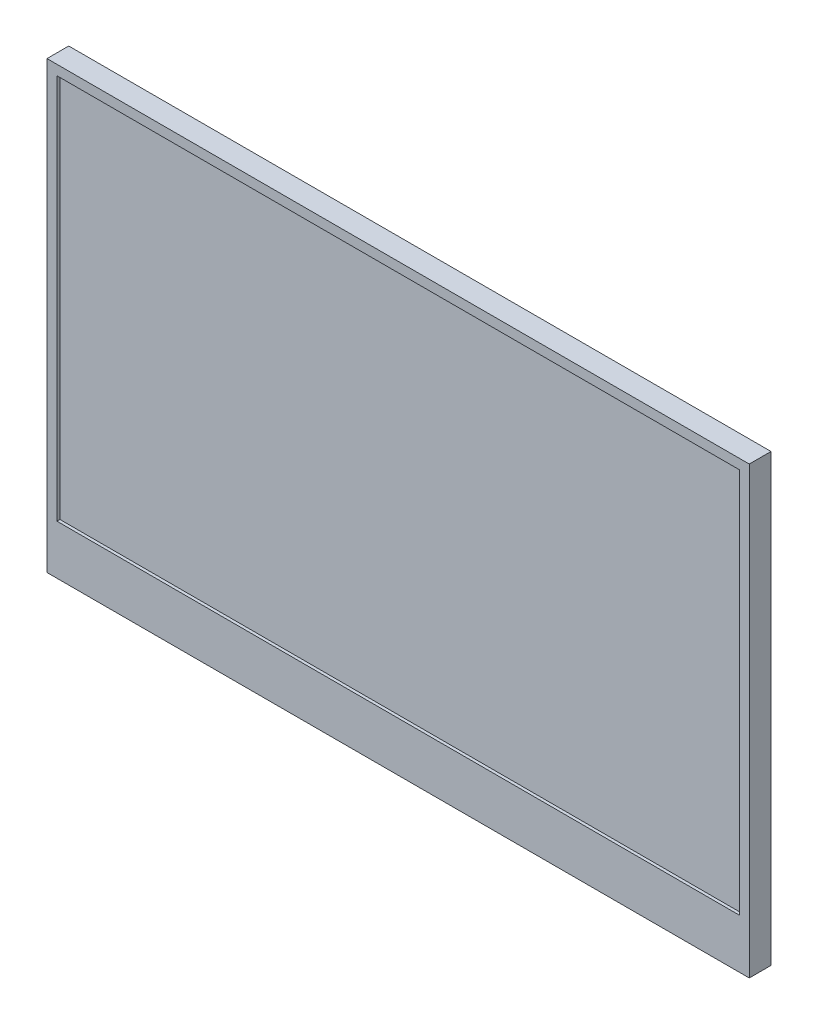
from build123d import *

# Parameters (mm, degrees)
SKETCH_2_W          = 355
SKETCH_2_H          = 225
EXTRUDE_2_DEPTH     = 11
SKETCH_4_W          = 345
SKETCH_4_H          = 195
CUT_EXTRUDE_2_DEPTH = 1.5


with BuildPart() as part:
    # 스케치2 → 보스-돌출2 (new body)
    with BuildSketch(Plane.XY):
        Rectangle(SKETCH_2_W, SKETCH_2_H)
    extrude(amount=EXTRUDE_2_DEPTH)

    # 스케치4 → 컷-돌출2 (cut)
    with BuildSketch(Plane.XY.offset(11)):
        with Locations((0, 10)):
            Rectangle(SKETCH_4_W, SKETCH_4_H)
    extrude(amount=-CUT_EXTRUDE_2_DEPTH, mode=Mode.SUBTRACT)


solid = part.part
